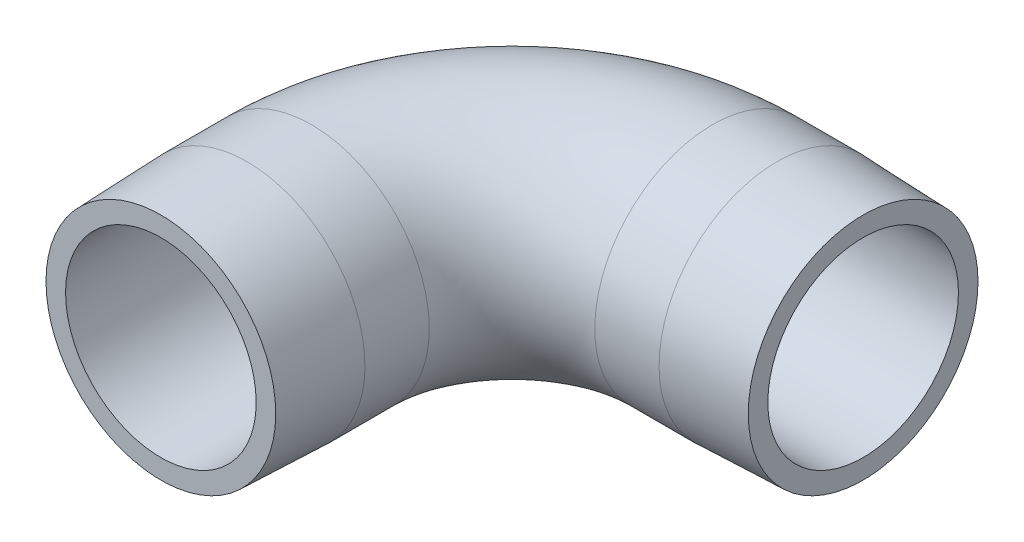
from build123d import *

# Parameters (mm, degrees)
SKETCH2_R          = 11.75
SKETCH2_R_2        = 9.5
SKETCH40_OUTSIDE_W = 63.83
SKETCH40_OUTSIDE_H = 40.58
SKETCH40_OUTSIDE_R = 11.45
CUT_EXTRUDE2_DEPTH = 15
CUT_EXTRUDE2_TAPER = 2
SKETCH41_OUTSIDE_W = 63.83
SKETCH41_OUTSIDE_H = 40.58
SKETCH41_OUTSIDE_R = 11.45
CUT_EXTRUDE3_DEPTH = 15
CUT_EXTRUDE3_TAPER = 2


with BuildPart() as part:
    # Sweep1: sweep along a path in Sketch1
    with BuildLine(Plane(origin=(0, 0, 0), x_dir=(1, 0, 0), z_dir=(0, 1, 0))) as sweep1_path:
        Line((0, 0), (0, 15))
        ThreePointArc((0, 15), (5.857864376, 29.142135624), (20, 35))
        Line((20, 35), (35, 35))
    # Sketch2 → Sweep1 (sweep)
    with BuildSketch(Plane.XY):
        Circle(SKETCH2_R)
        Circle(SKETCH2_R_2, mode=Mode.SUBTRACT)
    sweep(path=sweep1_path.line)

    # Sketch40 outside → Cut-Extrude2 (cut)
    with BuildSketch(Plane.XY):
        with Locations((11.625, 0)):
            Rectangle(SKETCH40_OUTSIDE_W, SKETCH40_OUTSIDE_H)
        Circle(SKETCH40_OUTSIDE_R, mode=Mode.SUBTRACT)
    extrude(amount=-CUT_EXTRUDE2_DEPTH, taper=CUT_EXTRUDE2_TAPER, mode=Mode.SUBTRACT)

    # Sketch41 outside → Cut-Extrude3 (cut)
    with BuildSketch(Plane(origin=(35, 0, 0), x_dir=(0, 0, -1), z_dir=(1, 0, 0))):
        with Locations((23.375, 0)):
            Rectangle(SKETCH41_OUTSIDE_W, SKETCH41_OUTSIDE_H)
        with Locations((35, 0)):
            Circle(SKETCH41_OUTSIDE_R, mode=Mode.SUBTRACT)
    extrude(amount=-CUT_EXTRUDE3_DEPTH, taper=CUT_EXTRUDE3_TAPER, mode=Mode.SUBTRACT)


solid = part.part
